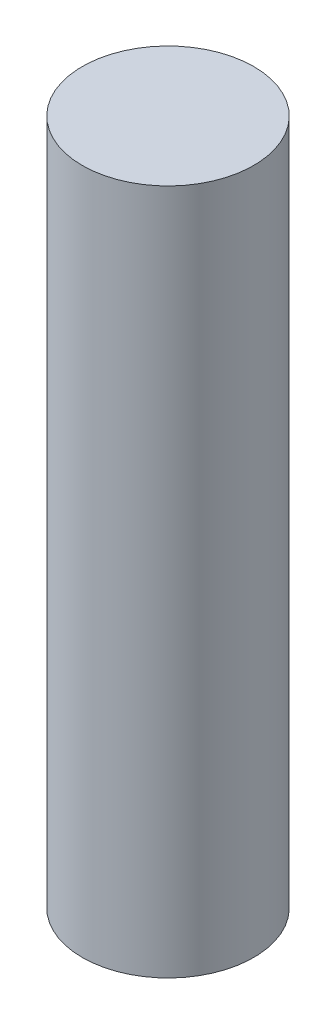
from build123d import *

# Parameters (mm, degrees)
SKETCH1_R           = 6.35
BOSS_EXTRUDE1_DEPTH = 50.8


with BuildPart() as part:
    # Sketch1 → Boss-Extrude1 (new body)
    with BuildSketch(Plane(origin=(0, 0, 0), x_dir=(1, 0, 0), z_dir=(0, 1, 0))):
        Circle(SKETCH1_R)
    extrude(amount=BOSS_EXTRUDE1_DEPTH)


solid = part.part
